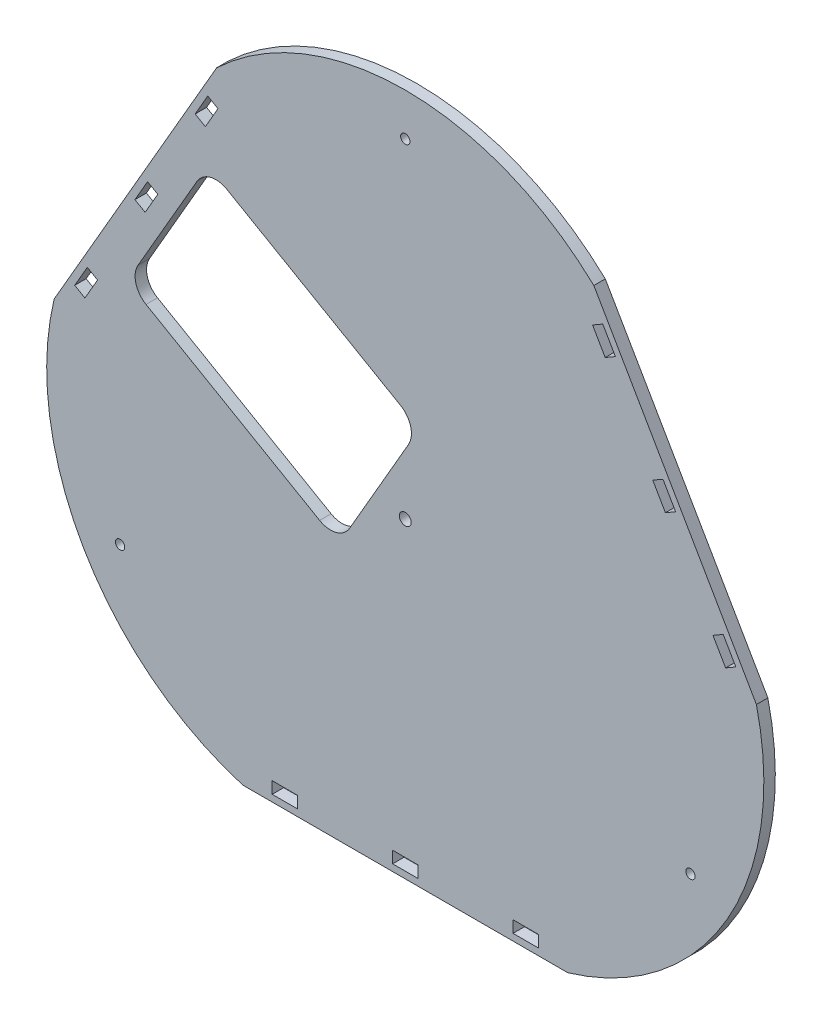
from build123d import *

# Parameters (mm, degrees)
SKETCH1_R           = 3.5
BOSS_EXTRUDE1_DEPTH = 6.8
SKETCH2_W           = 15
SKETCH2_H           = 7
CUT_EXTRUDE1_DEPTH  = 6.8
SKETCH3_R           = 2.75
CUT_EXTRUDE2_DEPTH  = 6.8
CIRPATTERN1_COUNT   = 3
CUT_EXTRUDE3_DEPTH  = 6.8
FILLET1_R           = 13


with BuildPart() as part:
    # Sketch1 → Boss-Extrude1 (new body)
    with BuildSketch(Plane.XY):
        with BuildLine():
            Line((-96.50625, -185), (96.50625, -185))
            ThreePointArc((96.50625, -185), (191.056759621, -110.306671598), (208.4678247, 8.923135876))
            Line((208.4678247, 8.923135876), (111.9615747, 176.076864124))
            ThreePointArc((111.9615747, 176.076864124), (0, 220.613343196), (-111.9615747, 176.076864124))
            Line((-111.9615747, 176.076864124), (-208.4678247, 8.923135876))
            ThreePointArc((-208.4678247, 8.923135876), (-191.056759621, -110.306671598), (-96.50625, -185))
        make_face()
        Circle(SKETCH1_R, mode=Mode.SUBTRACT)
    extrude(amount=BOSS_EXTRUDE1_DEPTH)

    # Sketch2 → Cut-Extrude1 (cut)
    with BuildSketch(Plane.XY.offset(6.8)):
        with Locations((0, -177.5)):
            Rectangle(SKETCH2_W, SKETCH2_H)
        with Locations((71.5, -177.5)):
            Rectangle(SKETCH2_W, SKETCH2_H)
        with Locations((-71.5, -177.5)):
            Rectangle(SKETCH2_W, SKETCH2_H)
    cut_extrude1 = extrude(amount=-CUT_EXTRUDE1_DEPTH, mode=Mode.SUBTRACT)

    # Sketch3 → Cut-Extrude2 (cut)
    with BuildSketch(Plane.XY.offset(6.8)):
        with Locations((0, 195.5)):
            Circle(SKETCH3_R)
    cut_extrude2 = extrude(amount=-CUT_EXTRUDE2_DEPTH, mode=Mode.SUBTRACT)

    # CirPattern1: Cut-Extrude1, Cut-Extrude2 ×3 about axis
    cirpattern1_axis = Axis((0, 0, 0), (0, 0, 1))
    for i in range(1, CIRPATTERN1_COUNT):
        add(cut_extrude1.rotate(cirpattern1_axis, i * 360 / CIRPATTERN1_COUNT), mode=Mode.SUBTRACT)
        add(cut_extrude2.rotate(cirpattern1_axis, i * 360 / CIRPATTERN1_COUNT), mode=Mode.SUBTRACT)

    # Sketch4 → Cut-Extrude3 (cut)
    with BuildSketch(Plane.XY.offset(6.8)):
        Polygon((-117.162140817, 123.069219382), (-165.162140817, 39.930780618), (-39.588457268, -32.569219382), (8.411542732, 50.569219382), align=None)
    extrude(amount=-CUT_EXTRUDE3_DEPTH, mode=Mode.SUBTRACT)

    # Fillet1
    fillet1_edges = [part.edges().sort_by_distance(p)[0] for p in [
        (-117.162140817, 123.069219382, 3.4),
        (8.411542732, 50.569219382, 3.4),
        (-39.588457268, -32.569219382, 3.4),
        (-165.162140817, 39.930780618, 3.4),
    ]]
    fillet(fillet1_edges, radius=FILLET1_R)


solid = part.part
